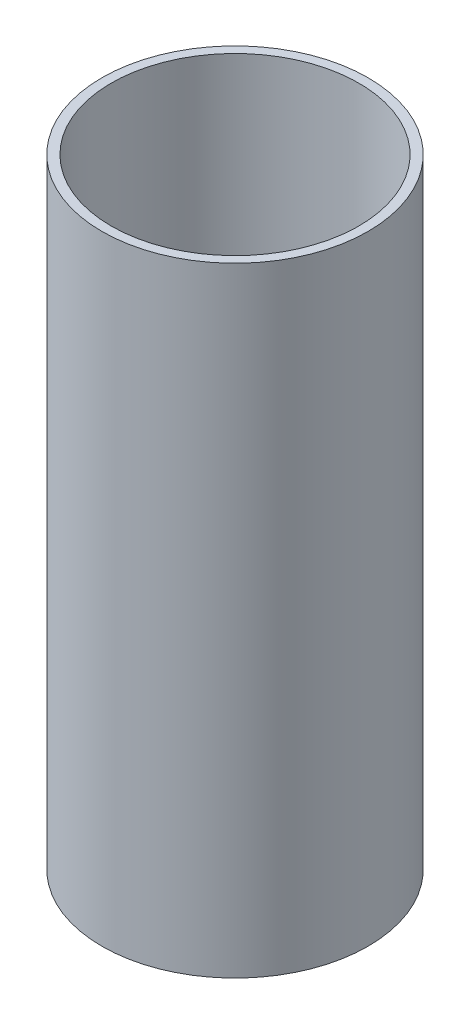
from build123d import *

# Parameters (mm, degrees)
SKETCH1_R           = 27.305
SKETCH1_R_2         = 25.4
BOSS_EXTRUDE1_DEPTH = 127


with BuildPart() as part:
    # Sketch1 → Boss-Extrude1 (new body)
    with BuildSketch(Plane(origin=(0, 0, 0), x_dir=(1, 0, 0), z_dir=(0, 1, 0))):
        Circle(SKETCH1_R)
        Circle(SKETCH1_R_2, mode=Mode.SUBTRACT)
    extrude(amount=BOSS_EXTRUDE1_DEPTH)


solid = part.part
